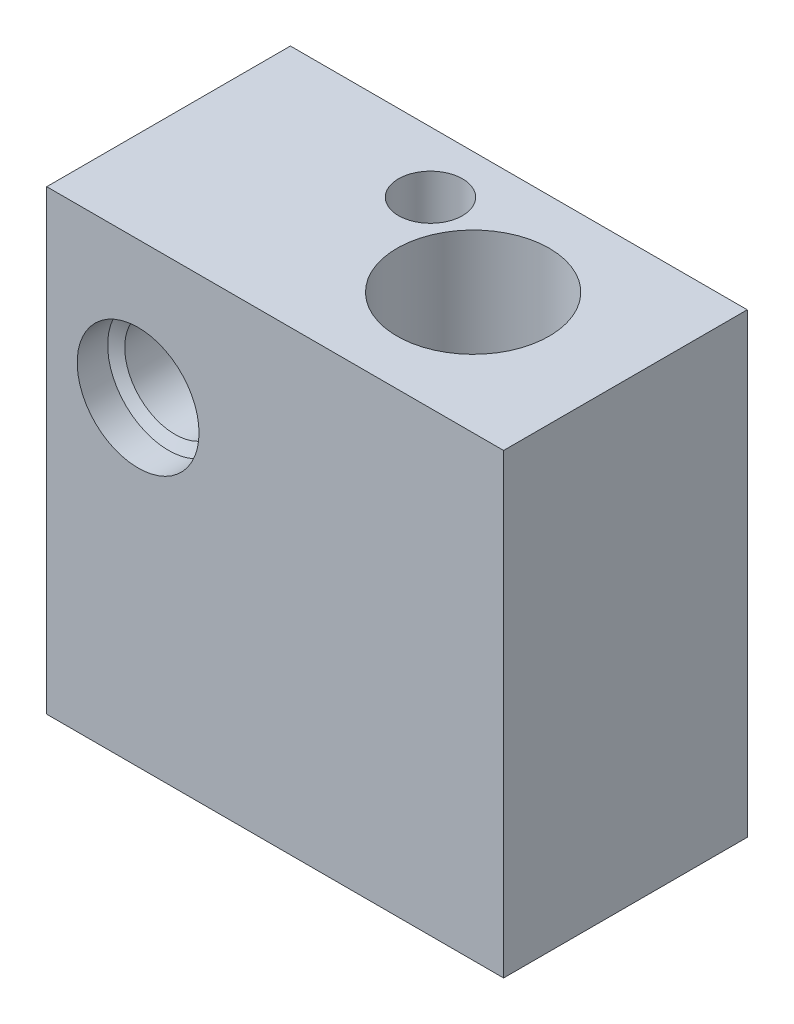
from build123d import *

# Parameters (mm, degrees)
SKETCH1_W                    = 15
SKETCH1_H                    = 15
SKETCH1_R                    = 1.65
BOSS_EXTRUDE1_DEPTH          = 8
SKETCH2_R                    = 2.5
CUT_EXTRUDE1_DEPTH           = 16
SKETCH3_R                    = 1.05
CUT_EXTRUDE2_DEPTH           = 16
F_4_0_4_DIAMETER_HOLE1_D     = 4
F_4_0_4_DIAMETER_HOLE1_DEPTH = 1
F_4_0_4_DIAMETER_HOLE1_TIP   = 1.201721238


with BuildPart() as part:
    # Sketch1 → Boss-Extrude1 (new body)
    with BuildSketch(Plane.XY):
        with Locations((4.5, -3)):
            Rectangle(SKETCH1_W, SKETCH1_H)
        Circle(SKETCH1_R, mode=Mode.SUBTRACT)
    extrude(amount=BOSS_EXTRUDE1_DEPTH)

    # Sketch2 → Cut-Extrude1 (cut, through all)
    with BuildSketch(Plane.XZ.offset(10.5)):
        with Locations((7, 4)):
            Circle(SKETCH2_R)
    extrude(amount=-CUT_EXTRUDE1_DEPTH, mode=Mode.SUBTRACT)

    # Sketch3 → Cut-Extrude2 (cut, through all)
    with BuildSketch(Plane.XZ.offset(10.5)):
        with Locations((3.6, 2)):
            Circle(SKETCH3_R)
    extrude(amount=-CUT_EXTRUDE2_DEPTH, mode=Mode.SUBTRACT)

    # Ø4.0 (4) Diameter Hole1
    with Locations(Plane.XY.offset(8)):
        with Locations((0, 0)):
            Hole(F_4_0_4_DIAMETER_HOLE1_D / 2, depth=F_4_0_4_DIAMETER_HOLE1_DEPTH)
            with Locations((0, 0, -(F_4_0_4_DIAMETER_HOLE1_DEPTH + F_4_0_4_DIAMETER_HOLE1_TIP / 2))):  # 118° drill point
                Cone(0, F_4_0_4_DIAMETER_HOLE1_D / 2, F_4_0_4_DIAMETER_HOLE1_TIP, mode=Mode.SUBTRACT)


solid = part.part
